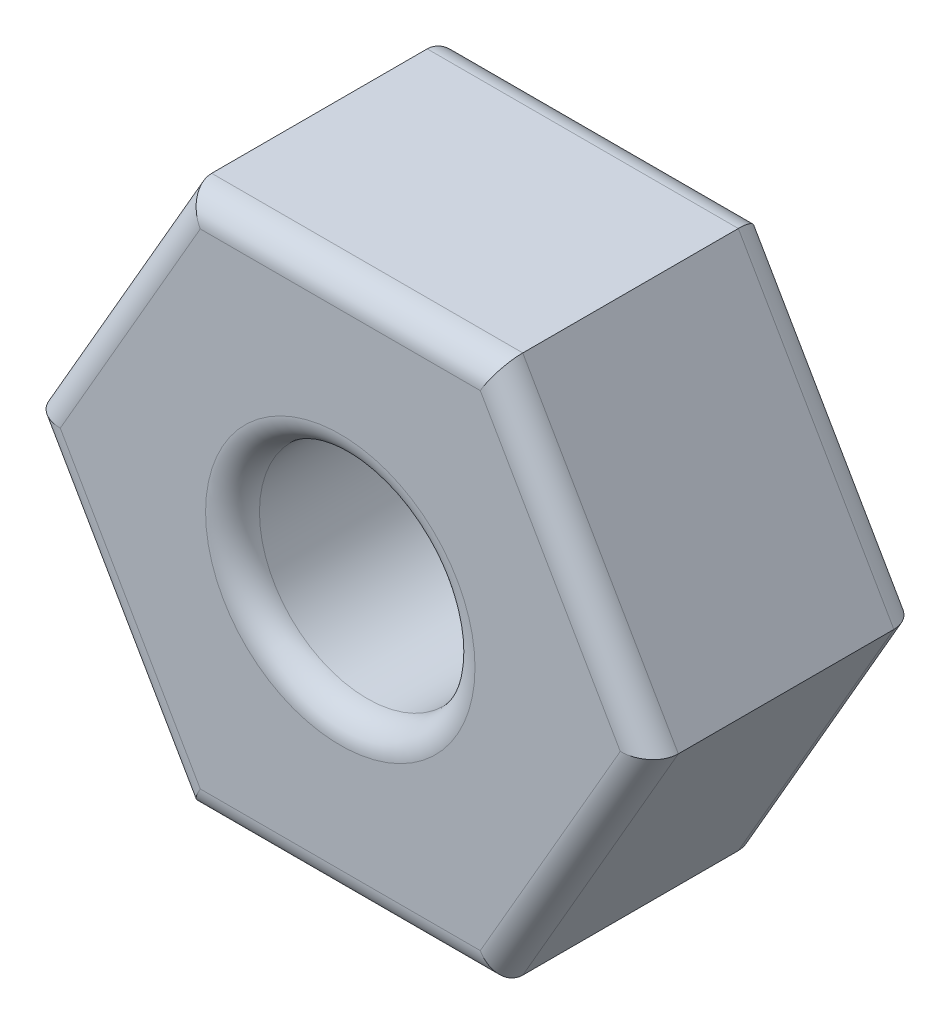
from build123d import *

# Parameters (mm, degrees)
SKETCH1_R           = 0.8
BOSS_EXTRUDE1_DEPTH = 2
FILLET1_R           = 0.2


with BuildPart() as part:
    # Sketch1 → Boss-Extrude1 (new body)
    with BuildSketch(Plane.XY):
        Polygon((2.309401077, 0), (1.154700538, 2), (-1.154700538, 2), (-2.309401077, 0), (-1.154700538, -2), (1.154700538, -2), align=None)
        Circle(SKETCH1_R, mode=Mode.SUBTRACT)
    extrude(amount=BOSS_EXTRUDE1_DEPTH)

    # Fillet1
    fillet1_edges = [part.edges().sort_by_distance(p)[0] for p in [
        (0, 2, 2),
        (-1.732050808, 1, 2),
        (-1.732050808, -1, 2),
        (-0.8, 0, 0),
        (-0.8, 0, 2),
        (0, -2, 2),
        (1.732050808, -1, 2),
        (0, -2, 0),
        (-1.732050808, -1, 0),
        (-1.732050808, 1, 0),
        (1.732050808, 1, 2),
        (0, 2, 0),
        (1.732050808, 1, 0),
        (1.732050808, -1, 0),
    ]]
    fillet(fillet1_edges, radius=FILLET1_R)


solid = part.part
